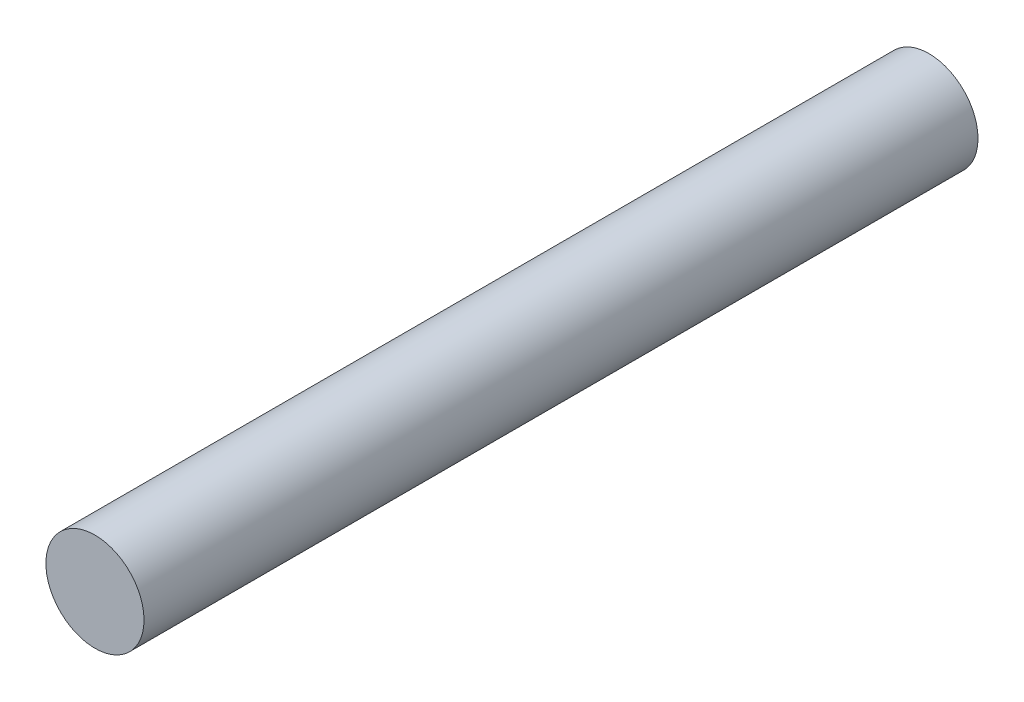
from build123d import *

# Parameters (mm, degrees)
SKETCH1_R           = 2.5
BOSS_EXTRUDE1_DEPTH = 42.5


with BuildPart() as part:
    # Sketch1 → Boss-Extrude1 (new body)
    with BuildSketch(Plane.XY):
        Circle(SKETCH1_R)
    extrude(amount=BOSS_EXTRUDE1_DEPTH)


solid = part.part
